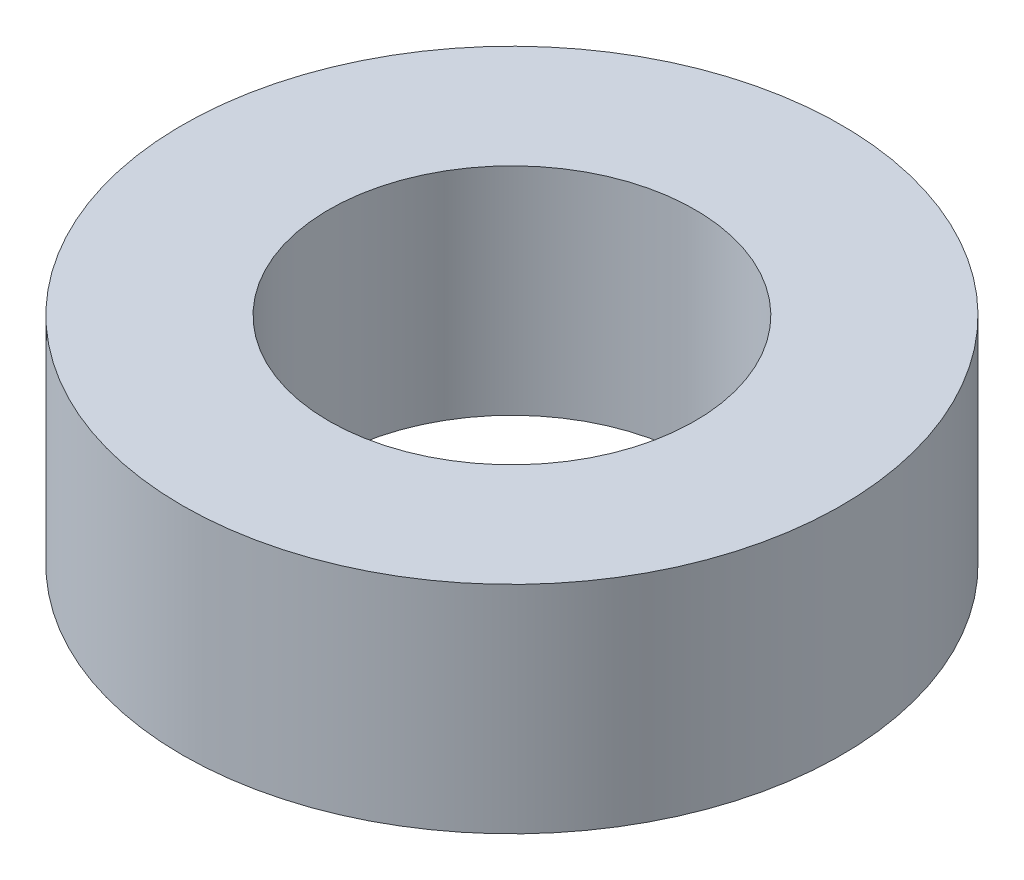
from build123d import *

# Parameters (mm, degrees)
SKETCH1_R           = 4.5
SKETCH1_R_2         = 2.5
BOSS_EXTRUDE1_DEPTH = 1.475


with BuildPart() as part:
    # Sketch1 → Boss-Extrude1 (new body, symmetric)
    with BuildSketch(Plane(origin=(0, 0, 0), x_dir=(1, 0, 0), z_dir=(0, 1, 0))):
        Circle(SKETCH1_R)
        Circle(SKETCH1_R_2, mode=Mode.SUBTRACT)
    extrude(amount=BOSS_EXTRUDE1_DEPTH, both=True)


solid = part.part
